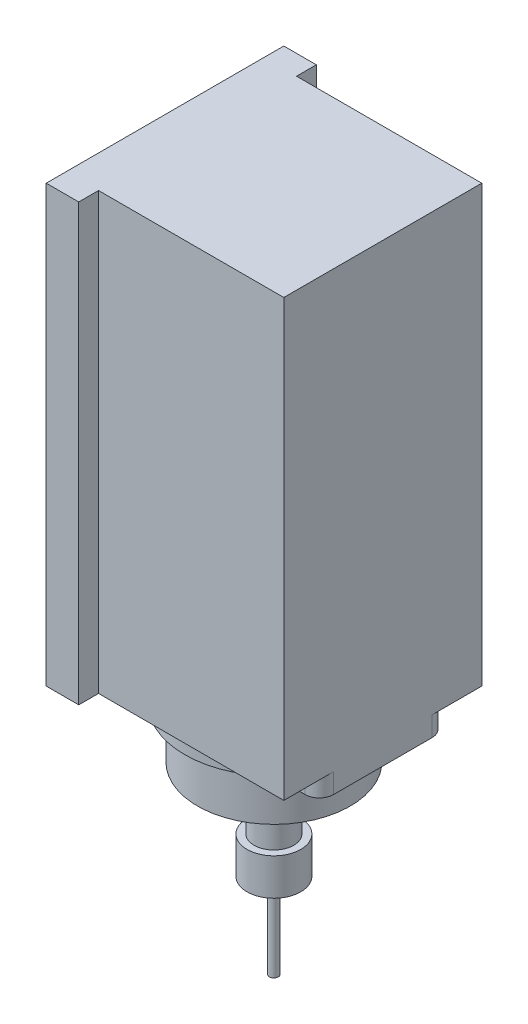
from build123d import *

# Parameters (mm, degrees)
BODY_EXTRUD_DEPTH   = 154
BOSS_EXTRUDE2_DEPTH = 7
SKETCH3_R           = 27
BOSS_EXTRUDE3_DEPTH = 18
SKETCH4_R           = 14.5
BOSS_EXTRUDE4_DEPTH = 3
SKETCH5_R           = 7
BOSS_EXTRUDE5_DEPTH = 19
SKETCH6_R           = 9.5
BOSS_EXTRUDE6_DEPTH = 13
SKETCH7_R           = 1.5875
BOSS_EXTRUDE7_DEPTH = 30


with BuildPart() as part:
    # Body → Body_extrud (new body)
    with BuildSketch(Plane(origin=(0, 0, 0), x_dir=(1, 0, 0), z_dir=(0, 1, 0))):
        Polygon((-38.5, -35), (-38.5, -42), (-27, -42), (-27, -35), (38.5, -35), (38.5, 35), (-27, 35), (-27, 42), (-38.5, 42), (-38.5, 35), align=None)
    extrude(amount=BODY_EXTRUD_DEPTH)

    # Sketch2 → Boss-Extrude2 (add)
    with BuildSketch(Plane.XZ):
        with BuildLine():
            Line((-33.5, 22.426470588), (-22.120203818, 22.426470588))
            ThreePointArc((-22.120203818, 22.426470588), (0, 31.5), (22.120203818, 22.426470588))
            Line((22.120203818, 22.426470588), (33.5, 22.426470588))
            ThreePointArc((33.5, 22.426470588), (37.035533906, 20.962004494), (38.5, 17.426470588))
            Line((38.5, 17.426470588), (38.5, -17.426470588))
            ThreePointArc((38.5, -17.426470588), (37.035533906, -20.962004494), (33.5, -22.426470588))
            Line((33.5, -22.426470588), (22.120203818, -22.426470588))
            ThreePointArc((22.120203818, -22.426470588), (0, -31.5), (-22.120203818, -22.426470588))
            Line((-22.120203818, -22.426470588), (-33.5, -22.426470588))
            ThreePointArc((-33.5, -22.426470588), (-37.035533906, -20.962004494), (-38.5, -17.426470588))
            Line((-38.5, -17.426470588), (-38.5, 17.426470588))
            ThreePointArc((-38.5, 17.426470588), (-37.035533906, 20.962004494), (-33.5, 22.426470588))
        make_face()
    extrude(amount=BOSS_EXTRUDE2_DEPTH)

    # Sketch3 → Boss-Extrude3 (add)
    with BuildSketch(Plane(origin=(0, -7, 0), x_dir=(-1, 0, 0), z_dir=(0, -1, 0))):
        Circle(SKETCH3_R)
    extrude(amount=BOSS_EXTRUDE3_DEPTH)

    # Sketch4 → Boss-Extrude4 (add)
    with BuildSketch(Plane(origin=(0, -25, 0), x_dir=(-1, 0, 0), z_dir=(0, -1, 0))):
        Circle(SKETCH4_R)
    extrude(amount=BOSS_EXTRUDE4_DEPTH)

    # Sketch5 → Boss-Extrude5 (add)
    with BuildSketch(Plane(origin=(0, -28, 0), x_dir=(-1, 0, 0), z_dir=(0, -1, 0))):
        Circle(SKETCH5_R)
    extrude(amount=BOSS_EXTRUDE5_DEPTH)

    # Sketch6 → Boss-Extrude6 (add)
    with BuildSketch(Plane.XZ.offset(47)):
        Circle(SKETCH6_R)
    extrude(amount=BOSS_EXTRUDE6_DEPTH)

    # Sketch7 → Boss-Extrude7 (add)
    with BuildSketch(Plane.XZ.offset(60)):
        Circle(SKETCH7_R)
    extrude(amount=BOSS_EXTRUDE7_DEPTH)


solid = part.part
